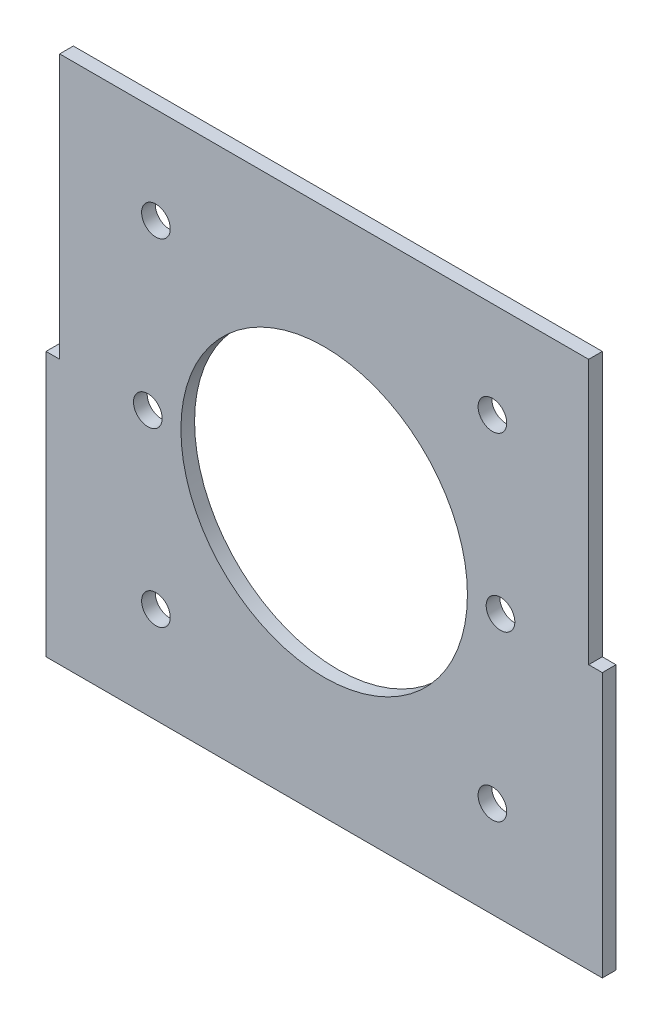
from build123d import *

# Parameters (mm, degrees)
SKETCH1_W           = 120
SKETCH1_H           = 120
SKETCH1_R           = 3.25
BOSS_EXTRUDE1_DEPTH = 3.1
SKETCH2_W           = 3.1
SKETCH2_H           = 60
BOSS_EXTRUDE3_DEPTH = 3.1
SKETCH5_R           = 32.5
CUT_EXTRUDE2_DEPTH  = 4.1


with BuildPart() as part:
    # Sketch1 → Boss-Extrude1 (new body)
    with BuildSketch(Plane.XY):
        Rectangle(SKETCH1_W, SKETCH1_H)
        with Locations((-38.166088515, 38.166088515)):
            Circle(SKETCH1_R, mode=Mode.SUBTRACT)
        with Locations((38.166088515, 38.166088515)):
            Circle(SKETCH1_R, mode=Mode.SUBTRACT)
        with Locations((38.166088515, -38.166088515)):
            Circle(SKETCH1_R, mode=Mode.SUBTRACT)
        with Locations((-38.166088515, -38.166088515)):
            Circle(SKETCH1_R, mode=Mode.SUBTRACT)
        with Locations((-40, 0)):
            Circle(SKETCH1_R, mode=Mode.SUBTRACT)
        with Locations((40, 0)):
            Circle(SKETCH1_R, mode=Mode.SUBTRACT)
    extrude(amount=BOSS_EXTRUDE1_DEPTH)

    # Sketch2 → Boss-Extrude3 (add, through all)
    with BuildSketch(Plane.XY.offset(3.1)):
        with Locations((61.55, -30)):
            Rectangle(SKETCH2_W, SKETCH2_H)
        with Locations((-61.55, -30)):
            Rectangle(SKETCH2_W, SKETCH2_H)
    extrude(amount=-BOSS_EXTRUDE3_DEPTH)

    # Sketch5 → Cut-Extrude2 (cut, through all)
    with BuildSketch(Plane.XY.offset(3.1)):
        Circle(SKETCH5_R)
    extrude(amount=-CUT_EXTRUDE2_DEPTH, mode=Mode.SUBTRACT)


solid = part.part
